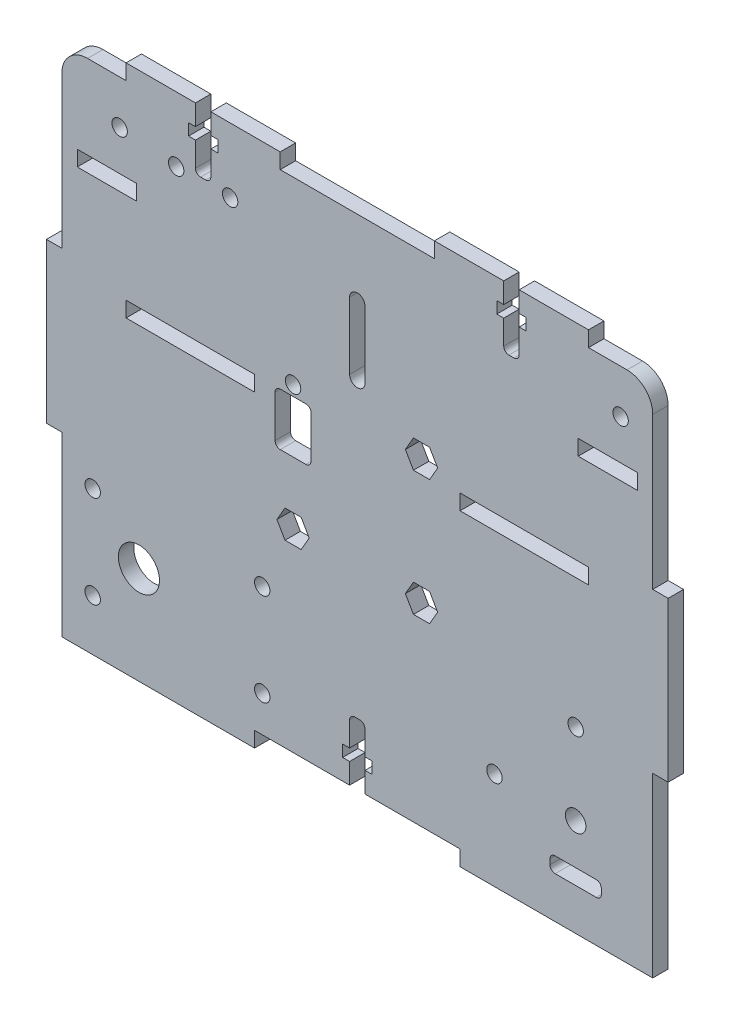
from build123d import *

# Parameters (mm, degrees)
ESBO_O1_W                   = 115
ESBO_O1_H                   = 100
RESSALTO_EXTRUS_O1_DEPTH    = 1.5
ESBO_O2_W                   = 40
ESBO_O2_H                   = 3
ESBO_O2_W_2                 = 25
CORTE_EXTRUS_O1_DEPTH       = 4
CUT_EXTRUDE12_DEPTH         = 2.5
CUT_EXTRUDE12_DEPTH_BACK    = 2.5
ESBO_O3_W                   = 3
ESBO_O3_H                   = 31
ESBO_O3_W_2                 = 30
ESBO_O3_H_2                 = 3
RESSALTO_EXTRUS_O2_DEPTH    = 3
ESBO_O30_R                  = 4
CORTE_EXTRUS_O11_DEPTH      = 1
CORTE_EXTRUS_O11_DEPTH_BACK = 4
ESBO_O4_R                   = 2
CORTE_EXTRUS_O2_DEPTH       = 4
ESBO_O31_R                  = 1.5
CORTE_EXTRUS_O12_DEPTH      = 1
CORTE_EXTRUS_O12_DEPTH_BACK = 4
CUT_EXTRUDE14_DEPTH         = 2.5
CUT_EXTRUDE14_DEPTH_BACK    = 2.5
SKETCH13_R                  = 1.5
CUT_EXTRUDE16_DEPTH         = 2.5
CUT_EXTRUDE16_DEPTH_BACK    = 2.5
CUT_EXTRUDE15_DEPTH         = 4
SKETCH12_3_W                = 4
SKETCH12_3_H                = 0.5
CUT_EXTRUDE18_DEPTH         = 0.1
FILLET1_R                   = 5
SKETCH14_R                  = 1.5
CUT_EXTRUDE17_DEPTH         = 2.5
CUT_EXTRUDE17_DEPTH_BACK    = 2.5
SKETCH15_R                  = 1.5
SKETCH15_W                  = 11.5
SKETCH15_H                  = 3
CORTE_GY_53LDK_DEPTH        = 2.5
CORTE_GY_53LDK_DEPTH_BACK   = 2.5
SKETCH17_R                  = 1.5
CUT_EXTRUDE20_DEPTH         = 1
CUT_EXTRUDE20_DEPTH_BACK    = 4


with BuildPart() as part:
    # Esboço1 → Ressalto-extrusão1 (new body, symmetric)
    with BuildSketch(Plane.XY):
        Rectangle(ESBO_O1_W, ESBO_O1_H)
    extrude(amount=RESSALTO_EXTRUS_O1_DEPTH, both=True)

    # Esboço2 → Corte-extrusão1 (cut, through all)
    with BuildSketch(Plane.XY.offset(1.5)):
        with Locations((0, -48.5)):
            Rectangle(ESBO_O2_W, ESBO_O2_H)
        with Locations((-32.5, 11.5)):
            Rectangle(ESBO_O2_W_2, ESBO_O2_H)
        with Locations((32.5, 11.5)):
            Rectangle(ESBO_O2_W_2, ESBO_O2_H)
    extrude(amount=-CORTE_EXTRUS_O1_DEPTH, mode=Mode.SUBTRACT)

    # Sketch9 → Cut-Extrude12 (cut, two sides)
    with BuildSketch(Plane.XY) as cut_extrude12_sk:
        with BuildLine():
            Line((-1.5, -47), (1.5, -47))
            Line((1.5, -47), (1.5, -43))
            Line((1.5, -43), (2.85, -43))
            Line((2.85, -43), (2.85, -40.73))
            Line((2.85, -40.73), (1.5, -40.73))
            Line((1.5, -40.73), (1.5, -36))
            ThreePointArc((1.5, -36), (1.207106781, -35.292893219), (0.5, -35))
            Line((0.5, -35), (-0.5, -35))
            ThreePointArc((-0.5, -35), (-1.207106781, -35.292893219), (-1.5, -36))
            Line((-1.5, -36), (-1.5, -40.73))
            Line((-1.5, -40.73), (-2.85, -40.73))
            Line((-2.85, -40.73), (-2.85, -43))
            Line((-2.85, -43), (-1.5, -43))
            Line((-1.5, -43), (-1.5, -47))
        make_face()
    extrude(amount=CUT_EXTRUDE12_DEPTH, mode=Mode.SUBTRACT)
    extrude(cut_extrude12_sk.sketch, amount=-CUT_EXTRUDE12_DEPTH_BACK, mode=Mode.SUBTRACT)

    # Esboço3 → Ressalto-extrusão2 (add, through all)
    with BuildSketch(Plane.XY.offset(1.5)):
        with Locations((59, 0)):
            Rectangle(ESBO_O3_W, ESBO_O3_H)
        with Locations((-59, 0)):
            Rectangle(ESBO_O3_W, ESBO_O3_H)
        with Locations((-30, 51.5)):
            Rectangle(ESBO_O3_W_2, ESBO_O3_H_2)
        with Locations((30, 51.5)):
            Rectangle(ESBO_O3_W_2, ESBO_O3_H_2)
    extrude(amount=-RESSALTO_EXTRUS_O2_DEPTH)

    # Esboço30 → Corte-extrusão11 (cut, two sides)
    with BuildSketch(Plane(origin=(0, 0, -1.5), x_dir=(-1, 0, 0), z_dir=(0, 0, -1))) as corte_extrus_o11_sk:
        with Locations((42.5, -31)):
            Circle(ESBO_O30_R)
    extrude(amount=CORTE_EXTRUS_O11_DEPTH, mode=Mode.SUBTRACT)
    extrude(corte_extrus_o11_sk.sketch, amount=-CORTE_EXTRUS_O11_DEPTH_BACK, mode=Mode.SUBTRACT)

    # Esboço4 → Corte-extrusão2 (cut, through all)
    with BuildSketch(Plane.XY.offset(1.5)):
        with Locations((42.5, -31)):
            Circle(ESBO_O4_R)
    extrude(amount=-CORTE_EXTRUS_O2_DEPTH, mode=Mode.SUBTRACT)

    # Esboço31 → Corte-extrusão12 (cut, two sides)
    with BuildSketch(Plane(origin=(0, 0, -1.5), x_dir=(-1, 0, 0), z_dir=(0, 0, -1))) as corte_extrus_o12_sk:
        with Locations((51.5, -22)):
            Circle(ESBO_O31_R)
        with Locations((51.5, -40)):
            Circle(ESBO_O31_R)
        with Locations((18.5, -22)):
            Circle(ESBO_O31_R)
        with Locations((18.5, -40)):
            Circle(ESBO_O31_R)
    extrude(amount=CORTE_EXTRUS_O12_DEPTH, mode=Mode.SUBTRACT)
    extrude(corte_extrus_o12_sk.sketch, amount=-CORTE_EXTRUS_O12_DEPTH_BACK, mode=Mode.SUBTRACT)

    # Sketch11 → Cut-Extrude14 (cut, two sides)
    with BuildSketch(Plane.XY) as cut_extrude14_sk:
        with BuildLine():
            Line((28.5, 53), (31.5, 53))
            Line((31.5, 53), (31.5, 49))
            Line((31.5, 49), (32.85, 49))
            Line((32.85, 49), (32.85, 46.73))
            Line((32.85, 46.73), (31.5, 46.73))
            Line((31.5, 46.73), (31.5, 42))
            ThreePointArc((31.5, 42), (31.207106781, 41.292893219), (30.5, 41))
            Line((30.5, 41), (29.5, 41))
            ThreePointArc((29.5, 41), (28.792893219, 41.292893219), (28.5, 42))
            Line((28.5, 42), (28.5, 46.73))
            Line((28.5, 46.73), (27.15, 46.73))
            Line((27.15, 46.73), (27.15, 49))
            Line((27.15, 49), (28.5, 49))
            Line((28.5, 49), (28.5, 53))
        make_face()
        with BuildLine():
            Line((-31.5, 46.73), (-32.85, 46.73))
            Line((-32.85, 46.73), (-32.85, 49))
            Line((-32.85, 49), (-31.5, 49))
            Line((-31.5, 49), (-31.5, 53))
            Line((-31.5, 53), (-28.5, 53))
            Line((-28.5, 53), (-28.5, 49))
            Line((-28.5, 49), (-27.15, 49))
            Line((-27.15, 49), (-27.15, 46.73))
            Line((-27.15, 46.73), (-28.5, 46.73))
            Line((-28.5, 46.73), (-28.5, 42))
            ThreePointArc((-28.5, 42), (-28.792893219, 41.292893219), (-29.5, 41))
            Line((-29.5, 41), (-30.5, 41))
            ThreePointArc((-30.5, 41), (-31.207106781, 41.292893219), (-31.5, 42))
            Line((-31.5, 42), (-31.5, 46.73))
        make_face()
    extrude(amount=CUT_EXTRUDE14_DEPTH, mode=Mode.SUBTRACT)
    extrude(cut_extrude14_sk.sketch, amount=-CUT_EXTRUDE14_DEPTH_BACK, mode=Mode.SUBTRACT)

    # Sketch13 → Cut-Extrude16 (cut, two sides)
    with BuildSketch(Plane.XY) as cut_extrude16_sk:
        with Locations((-12.5, 15.019319768)):
            Circle(SKETCH13_R)
        with BuildLine():
            Line((-10, 13.019319768), (-15, 13.019319768))
            ThreePointArc((-15, 13.019319768), (-15.707106781, 12.726426549), (-16, 12.019319768))
            Line((-16, 12.019319768), (-16, 3.819319768))
            ThreePointArc((-16, 3.819319768), (-15.707106781, 3.112212987), (-15, 2.819319768))
            Line((-15, 2.819319768), (-10, 2.819319768))
            ThreePointArc((-10, 2.819319768), (-9.292893219, 3.112212987), (-9, 3.819319768))
            Line((-9, 3.819319768), (-9, 12.019319768))
            ThreePointArc((-9, 12.019319768), (-9.292893219, 12.726426549), (-10, 13.019319768))
        make_face()
        Polygon((15.64, 15.019319768), (14.07, 17.738639536), (10.93, 17.738639536), (9.36, 15.019319768), (10.93, 12.3), (14.07, 12.3), align=None)
        Polygon((15.64, -9.280680232), (14.07, -6.561360464), (10.93, -6.561360464), (9.36, -9.280680232), (10.93, -12), (14.07, -12), align=None)
        Polygon((-9.36, -9.280680232), (-10.93, -6.561360464), (-14.07, -6.561360464), (-15.64, -9.280680232), (-14.07, -12), (-10.93, -12), align=None)
    extrude(amount=CUT_EXTRUDE16_DEPTH, mode=Mode.SUBTRACT)
    extrude(cut_extrude16_sk.sketch, amount=-CUT_EXTRUDE16_DEPTH_BACK, mode=Mode.SUBTRACT)

    # Sketch12 → Cut-Extrude15 (cut, through all)
    with BuildSketch(Plane.XY.offset(-1.5)):
        with BuildLine():
            Line((1.5, 22.238639536), (1.5, 35.238639536))
            ThreePointArc((1.5, 35.238639536), (0, 36.738639536), (-1.5, 35.238639536))
            Line((-1.5, 35.238639536), (-1.5, 22.238639536))
            ThreePointArc((-1.5, 22.238639536), (0, 20.738639536), (1.5, 22.238639536))
        make_face()
        with BuildLine():
            ThreePointArc((1.5, 35.238639536), (0, 36.738639536), (-1.5, 35.238639536))
            Line((-1.5, 35.238639536), (-1.5, 22.238639536))
            ThreePointArc((-1.5, 22.238639536), (0, 20.738639536), (1.5, 22.238639536))
            Line((1.5, 22.238639536), (1.5, 35.238639536))
        make_face()
    extrude(amount=CUT_EXTRUDE15_DEPTH, mode=Mode.SUBTRACT)

    # Sketch12_3 → Cut-Extrude18 (cut)
    with BuildSketch(Plane.XY.offset(-1.5)):
        with Locations((-4, 34.988639536)):
            Rectangle(SKETCH12_3_W, SKETCH12_3_H)
        with Locations((-4, 33.946972869)):
            Rectangle(SKETCH12_3_W, SKETCH12_3_H)
        with Locations((-4, 32.905306202)):
            Rectangle(SKETCH12_3_W, SKETCH12_3_H)
        with Locations((-4, 31.863639536)):
            Rectangle(SKETCH12_3_W, SKETCH12_3_H)
        with Locations((-4, 29.780306202)):
            Rectangle(SKETCH12_3_W, SKETCH12_3_H)
        with Locations((-4, 30.821972869)):
            Rectangle(SKETCH12_3_W, SKETCH12_3_H)
        with Locations((-4, 27.696972869)):
            Rectangle(SKETCH12_3_W, SKETCH12_3_H)
        with Locations((-4, 28.738639536)):
            Rectangle(SKETCH12_3_W, SKETCH12_3_H)
        with Locations((-4, 26.655306202)):
            Rectangle(SKETCH12_3_W, SKETCH12_3_H)
        with Locations((-4, 25.613639536)):
            Rectangle(SKETCH12_3_W, SKETCH12_3_H)
        with Locations((-4, 24.571972869)):
            Rectangle(SKETCH12_3_W, SKETCH12_3_H)
        with Locations((-4, 23.530306202)):
            Rectangle(SKETCH12_3_W, SKETCH12_3_H)
        with Locations((-4, 22.488639536)):
            Rectangle(SKETCH12_3_W, SKETCH12_3_H)
    extrude(amount=CUT_EXTRUDE18_DEPTH, mode=Mode.SUBTRACT)

    # Fillet1
    fillet1_edges = [part.edges().sort_by_distance(p)[0] for p in [
        (-57.5, 50, 0),
        (57.5, 50, 0),
    ]]
    fillet(fillet1_edges, radius=FILLET1_R)

    # Sketch14 → Cut-Extrude17 (cut, two sides)
    with BuildSketch(Plane.XY) as cut_extrude17_sk:
        with Locations((-24.75, 40.4)):
            Circle(SKETCH14_R)
        with Locations((-35.25, 40.4)):
            Circle(SKETCH14_R)
    extrude(amount=CUT_EXTRUDE17_DEPTH, mode=Mode.SUBTRACT)
    extrude(cut_extrude17_sk.sketch, amount=-CUT_EXTRUDE17_DEPTH_BACK, mode=Mode.SUBTRACT)

    # Sketch15 → Corte GY-53LDK (cut, two sides)
    with BuildSketch(Plane.XY) as corte_gy_53ldk_sk:
        with Locations((51.25, 41.5)):
            Circle(SKETCH15_R)
        with Locations((-46.25, 41.5)):
            Circle(SKETCH15_R)
        with Locations((48.75, 32.2)):
            Rectangle(SKETCH15_W, SKETCH15_H)
        with Locations((-48.75, 32.2)):
            Rectangle(SKETCH15_W, SKETCH15_H)
    extrude(amount=CORTE_GY_53LDK_DEPTH, mode=Mode.SUBTRACT)
    extrude(corte_gy_53ldk_sk.sketch, amount=-CORTE_GY_53LDK_DEPTH_BACK, mode=Mode.SUBTRACT)

    # Sketch17 → Cut-Extrude20 (cut, two sides)
    with BuildSketch(Plane(origin=(0, 0, -1.5), x_dir=(-1, 0, 0), z_dir=(0, 0, -1))) as cut_extrude20_sk:
        with Locations((-42.5, -15.2)):
            Circle(SKETCH17_R)
        with Locations((-26.7, -31)):
            Circle(SKETCH17_R)
        with BuildLine():
            Line((-46.5, -38.908712115), (-38.5, -38.908712115))
            ThreePointArc((-38.5, -38.908712115), (-37.792893219, -39.201605333), (-37.5, -39.908712115))
            Line((-37.5, -39.908712115), (-37.5, -40.908712115))
            ThreePointArc((-37.5, -40.908712115), (-37.792893219, -41.615818896), (-38.5, -41.908712115))
            Line((-38.5, -41.908712115), (-46.5, -41.908712115))
            ThreePointArc((-46.5, -41.908712115), (-47.207106781, -41.615818896), (-47.5, -40.908712115))
            Line((-47.5, -40.908712115), (-47.5, -39.908712115))
            ThreePointArc((-47.5, -39.908712115), (-47.207106781, -39.201605333), (-46.5, -38.908712115))
        make_face()
    extrude(amount=CUT_EXTRUDE20_DEPTH, mode=Mode.SUBTRACT)
    extrude(cut_extrude20_sk.sketch, amount=-CUT_EXTRUDE20_DEPTH_BACK, mode=Mode.SUBTRACT)


solid = part.part
